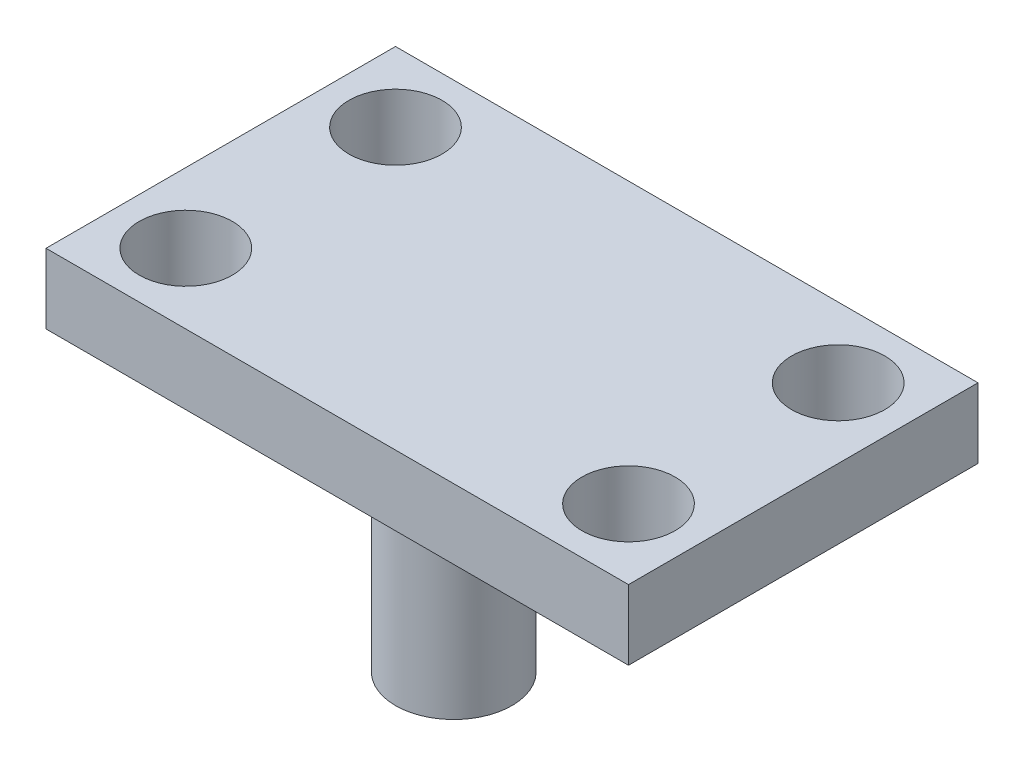
from build123d import *

# Parameters (mm, degrees)
SKETCH1_W           = 250
SKETCH1_H           = 150
SKETCH1_R           = 20
BOSS_EXTRUDE1_DEPTH = 30
SKETCH2_R           = 25
BOSS_EXTRUDE2_DEPTH = 120


with BuildPart() as part:
    # Sketch1 → Boss-Extrude1 (new body)
    with BuildSketch(Plane(origin=(0, 0, 0), x_dir=(1, 0, 0), z_dir=(0, 1, 0))):
        with Locations((125, 75)):
            Rectangle(SKETCH1_W, SKETCH1_H)
        with Locations((30, 120)):
            Circle(SKETCH1_R, mode=Mode.SUBTRACT)
        with Locations((30, 30)):
            Circle(SKETCH1_R, mode=Mode.SUBTRACT)
        with Locations((220, 120)):
            Circle(SKETCH1_R, mode=Mode.SUBTRACT)
        with Locations((220, 30)):
            Circle(SKETCH1_R, mode=Mode.SUBTRACT)
    extrude(amount=BOSS_EXTRUDE1_DEPTH)

    # Sketch2 → Boss-Extrude2 (add)
    with BuildSketch(Plane(origin=(0, 30, 0), x_dir=(1, 0, 0), z_dir=(0, 1, 0))):
        with Locations((125, 50)):
            Circle(SKETCH2_R)
    extrude(amount=-BOSS_EXTRUDE2_DEPTH)


solid = part.part
